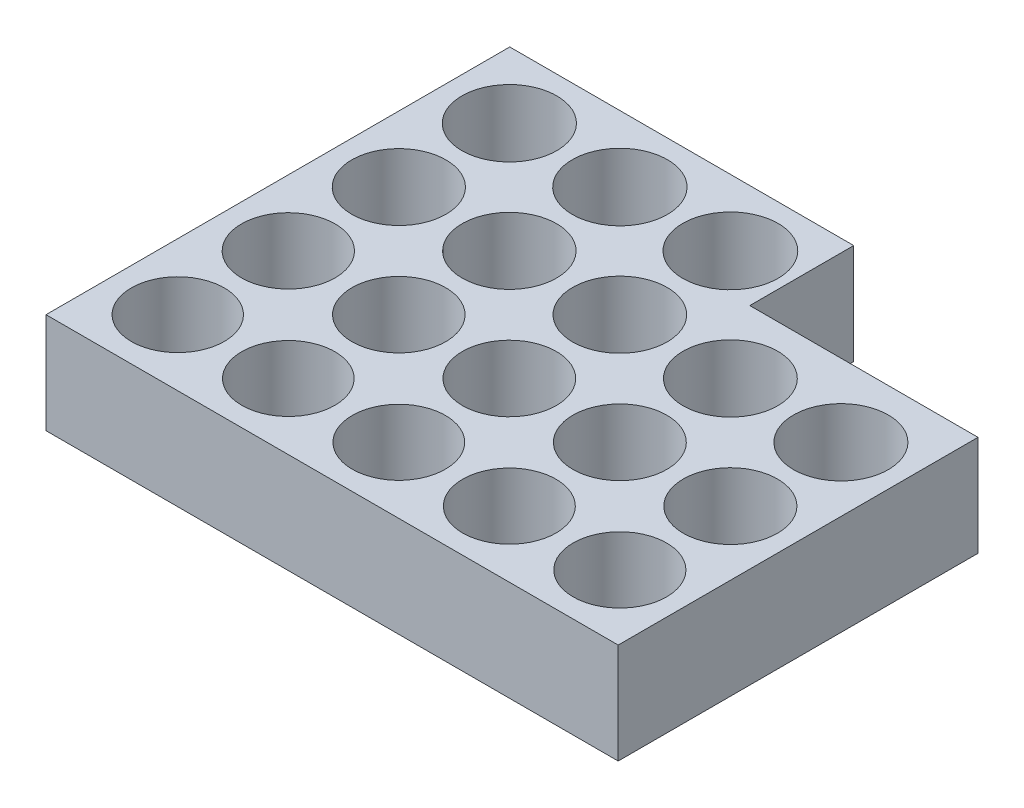
from build123d import *

# Parameters (mm, degrees)
SKETCH1_R           = 3.525
SKETCH1_R_2         = 3.53
SKETCH1_R_3         = 3.535
SKETCH1_R_4         = 3.54
SKETCH1_R_5         = 3.545
SKETCH1_R_6         = 3.555
SKETCH1_R_7         = 3.56
SKETCH1_R_8         = 3.565
SKETCH1_R_9         = 3.57
SKETCH1_R_10        = 3.58
SKETCH1_R_11        = 3.585
SKETCH1_R_12        = 3.59
SKETCH1_R_13        = 3.595
SKETCH1_R_14        = 3.605
SKETCH1_R_15        = 3.615
SKETCH1_R_16        = 3.55
SKETCH1_R_17        = 3.575
SKETCH1_R_18        = 3.6
BOSS_EXTRUDE1_DEPTH = 7.62


with BuildPart() as part:
    # Sketch1 → Boss-Extrude1 (new body)
    with BuildSketch(Plane(origin=(0, 0, 0), x_dir=(1, 0, 0), z_dir=(0, 1, 0))):
        Polygon((0, 0), (43.396152207, 0), (43.396152207, 27.288237387), (26.088694952, 27.288237387), (26.088694952, 35.171413764), (0, 35.171413764), align=None)
        with Locations((4.997445859, 4.997445859)):
            Circle(SKETCH1_R, mode=Mode.SUBTRACT)
        with Locations((13.379445859, 4.997445859)):
            Circle(SKETCH1_R_2, mode=Mode.SUBTRACT)
        with Locations((21.761445859, 4.997445859)):
            Circle(SKETCH1_R_3, mode=Mode.SUBTRACT)
        with Locations((30.143445859, 4.997445859)):
            Circle(SKETCH1_R_4, mode=Mode.SUBTRACT)
        with Locations((38.525445859, 4.997445859)):
            Circle(SKETCH1_R_5, mode=Mode.SUBTRACT)
        with Locations((13.379445859, 13.379445859)):
            Circle(SKETCH1_R_6, mode=Mode.SUBTRACT)
        with Locations((21.761445859, 13.379445859)):
            Circle(SKETCH1_R_7, mode=Mode.SUBTRACT)
        with Locations((30.143445859, 13.379445859)):
            Circle(SKETCH1_R_8, mode=Mode.SUBTRACT)
        with Locations((38.525445859, 13.379445859)):
            Circle(SKETCH1_R_9, mode=Mode.SUBTRACT)
        with Locations((13.379445859, 21.761445859)):
            Circle(SKETCH1_R_10, mode=Mode.SUBTRACT)
        with Locations((21.761445859, 21.761445859)):
            Circle(SKETCH1_R_11, mode=Mode.SUBTRACT)
        with Locations((30.143445859, 21.761445859)):
            Circle(SKETCH1_R_12, mode=Mode.SUBTRACT)
        with Locations((38.525445859, 21.761445859)):
            Circle(SKETCH1_R_13, mode=Mode.SUBTRACT)
        with Locations((13.379445859, 30.143445859)):
            Circle(SKETCH1_R_14, mode=Mode.SUBTRACT)
        with Locations((21.761445859, 30.143445859)):
            Circle(SKETCH1_R_15, mode=Mode.SUBTRACT)
        with Locations((4.997445859, 13.379445859)):
            Circle(SKETCH1_R_16, mode=Mode.SUBTRACT)
        with Locations((4.997445859, 21.761445859)):
            Circle(SKETCH1_R_17, mode=Mode.SUBTRACT)
        with Locations((4.997445859, 30.143445859)):
            Circle(SKETCH1_R_18, mode=Mode.SUBTRACT)
    extrude(amount=BOSS_EXTRUDE1_DEPTH)


solid = part.part
